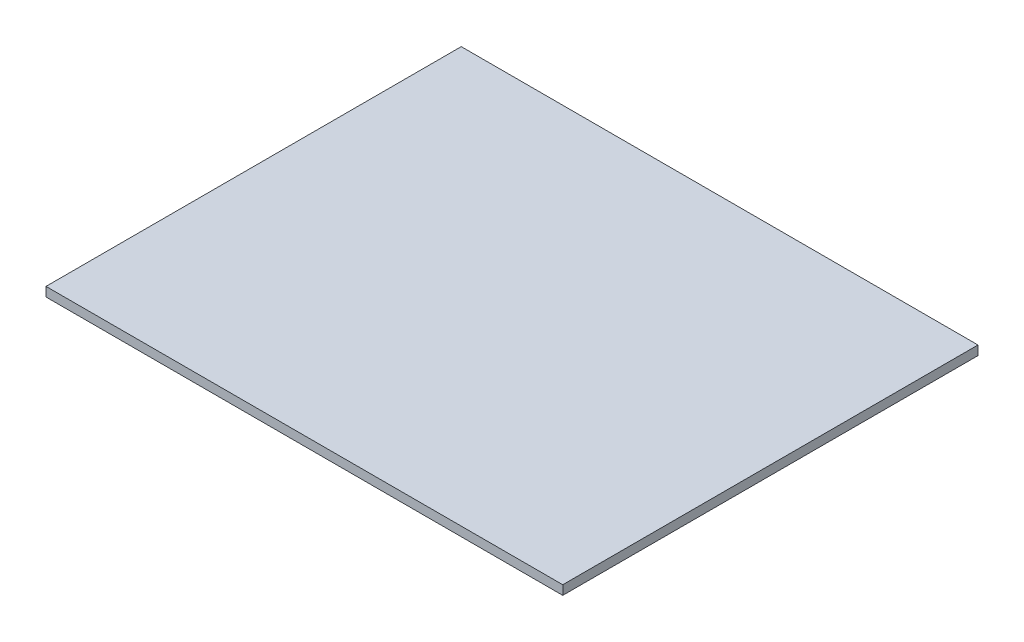
from build123d import *

# Parameters (mm, degrees)
SKETCH1_W           = 56
SKETCH1_H           = 45
BOSS_EXTRUDE1_DEPTH = 1


with BuildPart() as part:
    # Sketch1 → Boss-Extrude1 (new body)
    with BuildSketch(Plane(origin=(0, 0, 0), x_dir=(1, 0, 0), z_dir=(0, 1, 0))):
        Rectangle(SKETCH1_W, SKETCH1_H)
    extrude(amount=BOSS_EXTRUDE1_DEPTH)


solid = part.part
